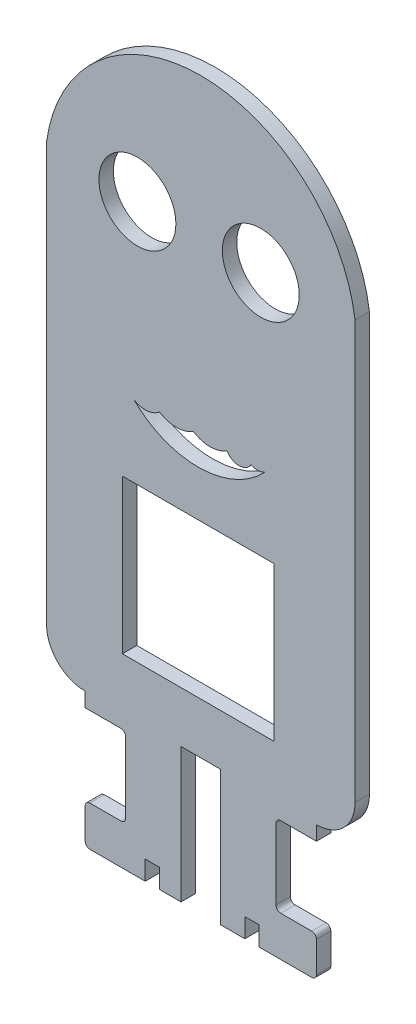
from build123d import *

# Parameters (mm, degrees)
MODEL_R                 = 8
SALIENTE_EXTRUIR1_DEPTH = 3


with BuildPart() as part:
    # Model → Saliente-Extruir1 (new body)
    with BuildSketch(Plane.XY):
        with BuildLine():
            Line((25.103364369, 60.449776828), (25.103364369, 55.560048431))
            Line((25.103364369, 55.560048431), (25.103364369, -26.439158767))
            ThreePointArc((25.103364369, -26.439158767), (22.813551952, -32.073921627), (17.210031036, -34.439158767))
            Line((17.210031036, -34.439158767), (17.077324369, -34.439158767))
            Line((17.077324369, -34.439158767), (17.077324369, -36.439158767))
            Line((17.077324369, -36.439158767), (17.077324369, -37.439158767))
            Line((17.077324369, -37.439158767), (9.634620202, -37.439158767))
            ThreePointArc((9.634620202, -37.439158767), (8.940767121, -37.73835668), (8.658097702, -38.439105914))
            Line((8.658097702, -38.439105914), (8.658097702, -53.106951569))
            ThreePointArc((8.658097702, -53.106951569), (8.944324254, -53.811296927), (9.644764369, -54.106951569))
            Line((9.644764369, -54.106951569), (16.090657702, -54.106951569))
            ThreePointArc((16.090657702, -54.106951569), (16.791097817, -54.402606212), (17.077324369, -55.106951569))
            Line((17.077324369, -55.106951569), (17.077324369, -61.439951569))
            ThreePointArc((17.077324369, -61.439951569), (16.791097817, -62.144296927), (16.090657702, -62.439951569))
            Line((16.090657702, -62.439951569), (5.154444792, -62.439951569))
            Line((5.154444792, -62.439951569), (5.154444792, -58.439951569))
            Line((5.154444792, -58.439951569), (2.194444792, -58.439951569))
            Line((2.194444792, -58.439951569), (2.194444792, -62.439951569))
            Line((2.194444792, -62.439951569), (-2.852355631, -62.439951569))
            Line((-2.852355631, -62.439951569), (-2.852355631, -34.439951569))
            Line((-2.852355631, -34.439951569), (-11.074248964, -34.439951569))
            Line((-11.074248964, -34.439951569), (-11.074248964, -62.439951569))
            Line((-11.074248964, -62.439951569), (-15.565555208, -62.439951569))
            Line((-15.565555208, -62.439951569), (-15.565555208, -58.439951569))
            Line((-15.565555208, -58.439951569), (-18.525555208, -58.439951569))
            Line((-18.525555208, -58.439951569), (-18.525555208, -62.439951569))
            Line((-18.525555208, -62.439951569), (-30.017262298, -62.439951569))
            ThreePointArc((-30.017262298, -62.439951569), (-30.717702412, -62.144296927), (-31.003928964, -61.439951569))
            Line((-31.003928964, -61.439951569), (-31.003928964, -55.106951569))
            ThreePointArc((-31.003928964, -55.106951569), (-30.717702412, -54.402606212), (-30.017262298, -54.106951569))
            Line((-30.017262298, -54.106951569), (-23.571368964, -54.106951569))
            ThreePointArc((-23.571368964, -54.106951569), (-22.87092885, -53.811296927), (-22.584702298, -53.106951569))
            Line((-22.584702298, -53.106951569), (-22.584702298, -38.439951569))
            ThreePointArc((-22.584702298, -38.439951569), (-22.87092885, -37.735606212), (-23.571368964, -37.439951569))
            Line((-23.571368964, -37.439951569), (-31.003928964, -37.439951569))
            Line((-31.003928964, -37.439951569), (-31.003928964, -34.439951569))
            Line((-31.003928964, -34.439951569), (-31.136635631, -34.439951569))
            ThreePointArc((-31.136635631, -34.439951569), (-36.740156547, -32.074714429), (-39.029968964, -26.439951569))
            Line((-39.029968964, -26.439951569), (-39.029968964, 60.449776828))
            ThreePointArc((-39.029968964, 60.449776828), (-11.813715639, 88.05803587), (22.36143002, 69.755035253))
            ThreePointArc((22.36143002, 69.755035253), (24.083000637, 65.205716618), (25.103364369, 60.449776828))
        make_face()
        with Locations((5.510677067, 59.135571807)):
            Circle(MODEL_R, mode=Mode.SUBTRACT)
        with Locations((-20.142656266, 59.135571807)):
            Circle(MODEL_R, mode=Mode.SUBTRACT)
        Polygon((8.30541929, 8.146386979), (-6.981247377, 8.146386979), (-23.267914044, 8.146386979), (-23.267914044, -23.853613021), (8.30541929, -23.853613021), align=None, mode=Mode.SUBTRACT)
        with BuildLine():
            ThreePointArc((3.470031036, 23.560048431), (5.034204267, 23.261828431), (6.524349919, 23.823111786))
            ThreePointArc((6.524349919, 23.823111786), (-7.083808204, 17.640131856), (-20.962959728, 23.188137015))
            ThreePointArc((-20.962959728, 23.188137015), (-18.18444232, 22.468056811), (-15.529968964, 23.560048431))
            ThreePointArc((-15.529968964, 23.560048431), (-12.029968964, 22.540846026), (-8.529968964, 23.560048431))
            ThreePointArc((-8.529968964, 23.560048431), (-5.029968964, 22.540846026), (-1.529968964, 23.560048431))
            ThreePointArc((-1.529968964, 23.560048431), (0.970031036, 22.144572483), (3.470031036, 23.560048431))
        make_face(mode=Mode.SUBTRACT)
    extrude(amount=SALIENTE_EXTRUIR1_DEPTH)


solid = part.part
